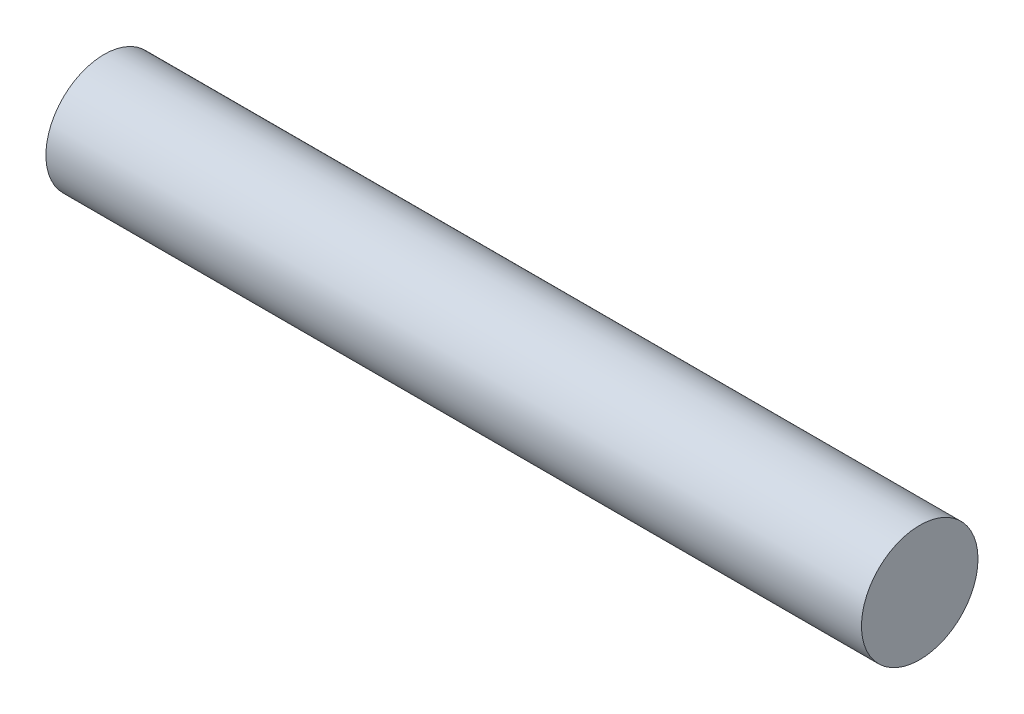
from build123d import *

# Parameters (mm, degrees)
SKETCH_1_R      = 2.5
EXTRUDE_1_DEPTH = 35


with BuildPart() as part:
    # 草图1 → 凸台-拉伸1 (new body)
    with BuildSketch(Plane(origin=(0, 0, 0), x_dir=(0, 0, -1), z_dir=(1, 0, 0))):
        Circle(SKETCH_1_R)
    extrude(amount=EXTRUDE_1_DEPTH)


solid = part.part
